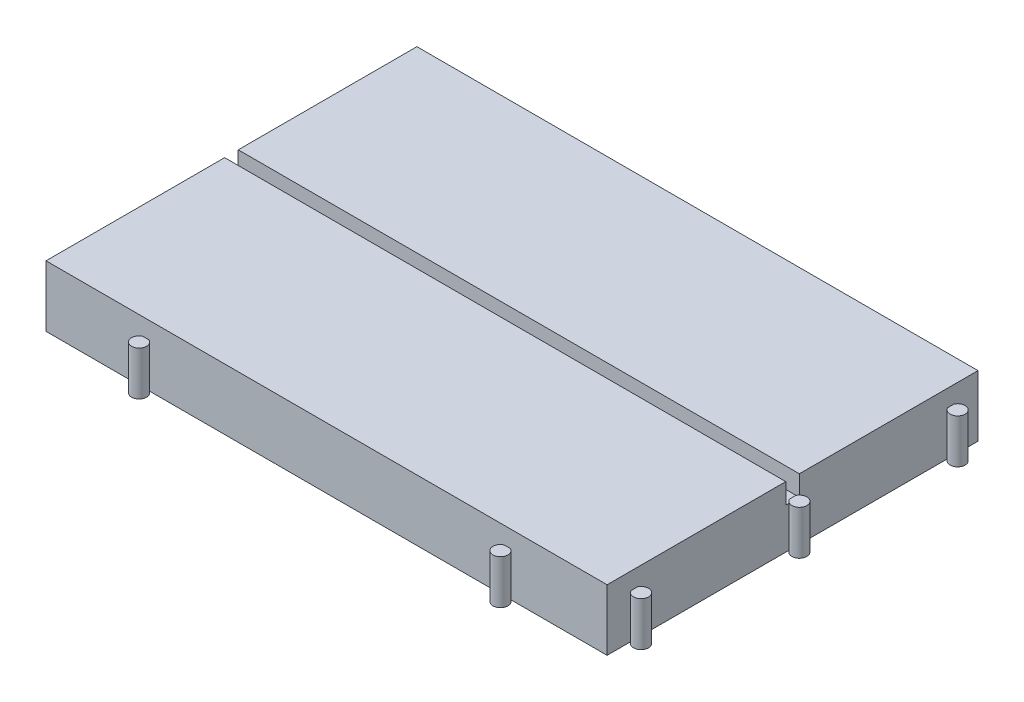
from build123d import *

# Parameters (mm, degrees)
BOSS_EXTRUDE1_DEPTH = 6
SKETCH2_W           = 82.6
SKETCH2_H           = 26.3
BOSS_EXTRUDE2_DEPTH = 3
SKETCH3_W           = 82.6
SKETCH3_H           = 26.3
BOSS_EXTRUDE3_DEPTH = 3
BOSS_EXTRUDE4_DEPTH = 0.5
BOSS_EXTRUDE5_DEPTH = 6.5
BOSS_EXTRUDE6_DEPTH = 6.5
BOSS_EXTRUDE7_DEPTH = 6.5
BOSS_EXTRUDE8_DEPTH = 6.5


with BuildPart() as part:
    # Sketch1 → Boss-Extrude1 (new body)
    with BuildSketch(Plane.XZ):
        with BuildLine():
            Line((-82.6, 0), (0, 0))
            Line((0, 0), (0, 26.841742431))
            ThreePointArc((0, 26.841742431), (2.1, 27.3), (0, 27.758257569))
            Line((0, 27.758257569), (0, 54.6))
            Line((0, 54.6), (-82.6, 54.6))
            Line((-82.6, 54.6), (-82.6, 0))
        make_face()
    extrude(amount=-BOSS_EXTRUDE1_DEPTH)

    # Sketch2 → Boss-Extrude2 (add)
    with BuildSketch(Plane(origin=(0, 6, 0), x_dir=(-1, 0, 0), z_dir=(0, 1, 0))):
        with Locations((41.3, 13.15)):
            Rectangle(SKETCH2_W, SKETCH2_H)
    extrude(amount=BOSS_EXTRUDE2_DEPTH)

    # Sketch3 → Boss-Extrude3 (add)
    with BuildSketch(Plane(origin=(0, 6, 0), x_dir=(-1, 0, 0), z_dir=(0, 1, 0))):
        with Locations((41.3, 41.45)):
            Rectangle(SKETCH3_W, SKETCH3_H)
    extrude(amount=BOSS_EXTRUDE3_DEPTH)

    # Sketch4 → Boss-Extrude4 (add)
    with BuildSketch(Plane(origin=(0, 6, 0), x_dir=(-1, 0, 0), z_dir=(0, 1, 0))):
        with BuildLine():
            Line((0, 27.758257569), (0, 26.841742431))
            ThreePointArc((0, 26.841742431), (-2.1, 27.3), (0, 27.758257569))
        make_face()
    extrude(amount=BOSS_EXTRUDE4_DEPTH)

    # Sketch5 → Boss-Extrude5 (add)
    with BuildSketch(Plane.XZ):
        with BuildLine():
            Line((0, 4.458257629), (0, 3.54174249))
            ThreePointArc((0, 3.54174249), (2.1, 4.00000006), (0, 4.458257629))
        make_face()
    extrude(amount=-BOSS_EXTRUDE5_DEPTH)

    # Sketch6 → Boss-Extrude6 (add)
    with BuildSketch(Plane.XZ):
        with BuildLine():
            Line((0, 51.05825751), (0, 50.141742371))
            ThreePointArc((0, 50.141742371), (2.1, 50.59999994), (0, 51.05825751))
        make_face()
    extrude(amount=-BOSS_EXTRUDE6_DEPTH)

    # Sketch7 → Boss-Extrude7 (add)
    with BuildSketch(Plane.XZ):
        with BuildLine():
            Line((-68.358257569, 54.6), (-67.441742431, 54.6))
            ThreePointArc((-67.441742431, 54.6), (-67.9, 56.7), (-68.358257569, 54.6))
        make_face()
    extrude(amount=-BOSS_EXTRUDE7_DEPTH)

    # Sketch8 → Boss-Extrude8 (add)
    with BuildSketch(Plane.XZ):
        with BuildLine():
            Line((-15.158257569, 54.6), (-14.241742431, 54.6))
            ThreePointArc((-14.241742431, 54.6), (-14.7, 56.7), (-15.158257569, 54.6))
        make_face()
    extrude(amount=-BOSS_EXTRUDE8_DEPTH)


solid = part.part
